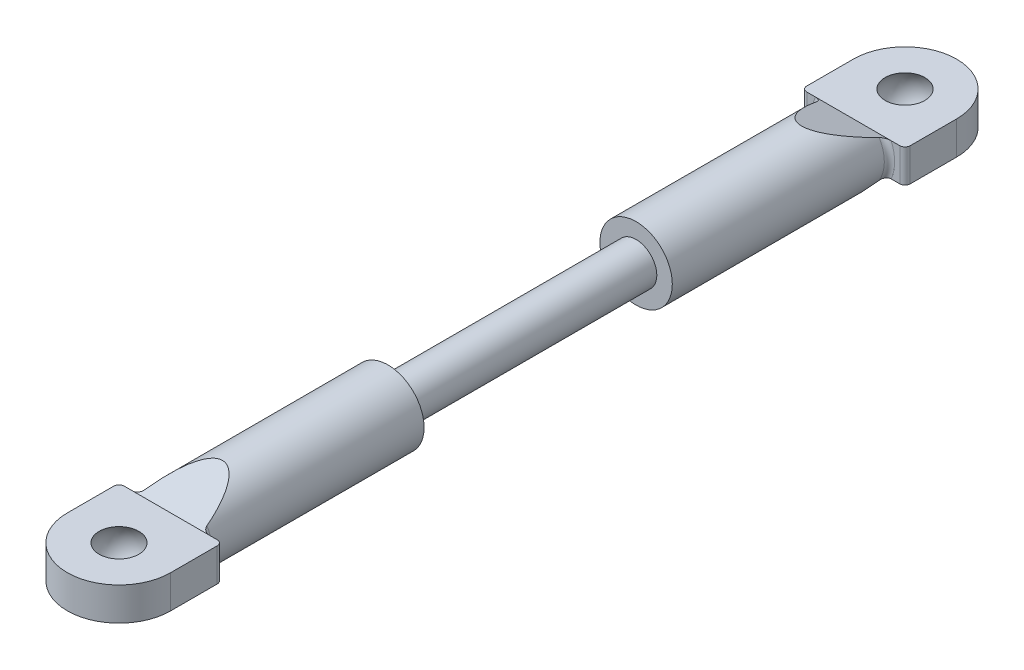
from build123d import *

# Parameters (mm, degrees)
SKETCH1_R                  = 2
SCREW_SECTION_DEPTH        = 12
SKETCH2_R                  = 3.5
BAR_SECTION_DEPTH          = 21
MOUNT_SECTION_DEPTH        = 1.6
BAR_TAPER_DEPTH            = 6
MOUNT_FILLET_R             = 0.5
MOUNT_FILLET_OF_MIRROR_2_R = 0.5


with BuildPart() as part:
    # Sketch1 → Screw Section (new body)
    with BuildSketch(Plane.XY):
        Circle(SKETCH1_R)
    screw_section = extrude(amount=SCREW_SECTION_DEPTH)

    # Sketch2 → Bar Section (add)
    with BuildSketch(Plane.XY.offset(12)):
        Circle(SKETCH2_R)
    bar_section = extrude(amount=BAR_SECTION_DEPTH)

    # Sketch3 → Mount Section (add, symmetric)
    with BuildSketch(Plane(origin=(0, 0, 0), x_dir=(1, 0, 0), z_dir=(0, 1, 0))):
        with BuildLine():
            Line((5, -33), (-5, -33))
            Line((-5, -33), (-5, -38))
            ThreePointArc((-5, -38), (0, -43), (5, -38))
            Line((5, -38), (5, -33))
        make_face()
    mount_section = extrude(amount=MOUNT_SECTION_DEPTH, both=True)

    # Sketch4 → Bar Taper (cut, symmetric)
    with BuildSketch(Plane(origin=(0, 0, 0), x_dir=(0, 0, -1), z_dir=(1, 0, 0))):
        Polygon((-28, -3.5), (-33, -1.6), (-33, -3.5), align=None)
        Polygon((-28, 3.5), (-33, 1.6), (-33, 3.5), align=None)
    bar_taper = extrude(amount=BAR_TAPER_DEPTH, both=True, mode=Mode.SUBTRACT)

    # Mount Fillet
    mount_fillet_edges = [part.edges().sort_by_distance(p)[0] for p in [
        (-5, 0, 33),
        (3.401842713, -0.823083322, 33),
        (-3.5, 0, 33),
        (5, 0, 33),
    ]]
    fillet(mount_fillet_edges, radius=MOUNT_FILLET_R)

    # Sketch6 → Ball Hole (revolve, cut)
    with BuildSketch(Plane(origin=(0, 0, 0), x_dir=(0, 0, -1), z_dir=(1, 0, 0))):
        with BuildLine():
            Line((-39.920937271, -1.6), (-38, -1.6))
            Line((-38, -1.6), (-38, 1.6))
            Line((-38, 1.6), (-39.920937271, 1.6))
            ThreePointArc((-39.920937271, 1.6), (-40.5, 0), (-39.920937271, -1.6))
        make_face()
    ball_hole = revolve(axis=Axis((0, -1.6, 38), (0, 1, 0)), mode=Mode.SUBTRACT)

    # Mirror 2: Screw Section, Bar Section, Mount Section, Bar Taper, Ball Hole across plane
    add(screw_section.mirror(Plane.XY))
    add(bar_section.mirror(Plane.XY))
    add(mount_section.mirror(Plane.XY))
    add(bar_taper.mirror(Plane.XY), mode=Mode.SUBTRACT)
    add(ball_hole.mirror(Plane.XY), mode=Mode.SUBTRACT)

    # Mount Fillet of Mirror 2
    mount_fillet_of_mirror_2_edges = [part.edges().sort_by_distance(p)[0] for p in [
        (-5, 0, -33),
        (3.401842713, -0.823083322, -33),
        (-3.5, 0, -33),
        (5, 0, -33),
    ]]
    fillet(mount_fillet_of_mirror_2_edges, radius=MOUNT_FILLET_OF_MIRROR_2_R)


solid = part.part
